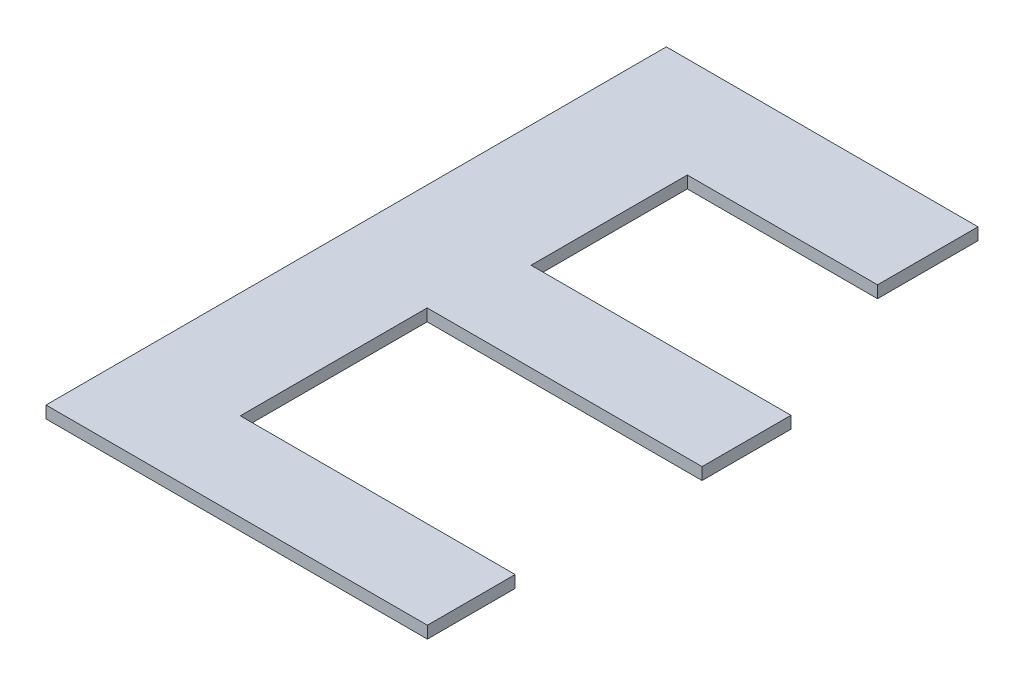
from build123d import *

# Parameters (mm, degrees)
BOSS_EXTRUDE1_START = 500
BOSS_EXTRUDE1_DEPTH = 20


with BuildPart() as part:
    # Sketch2 → Boss-Extrude1 (new body)
    with BuildSketch(Plane.XZ.offset(-6587.857128547).offset(BOSS_EXTRUDE1_START)):
        Polygon((-23417.771071287, 41050.141416955), (-23417.771071287, 40189.100196056), (-23417.771071287, 40022.680514279), (-22901.561141737, 40022.680514279), (-22901.561141737, 40189.100196056), (-23216.614310756, 40189.100196056), (-23216.614310756, 40447.924756229), (-22786.083114137, 40447.924756229), (-22786.083114137, 40595.178045331), (-23241.381102723, 40595.178045331), (-23241.381102723, 40904.737128326), (-22786.083114137, 40904.737128326), (-22786.083114137, 41050.141416955), align=None)
    extrude(amount=BOSS_EXTRUDE1_DEPTH)


solid = part.part
